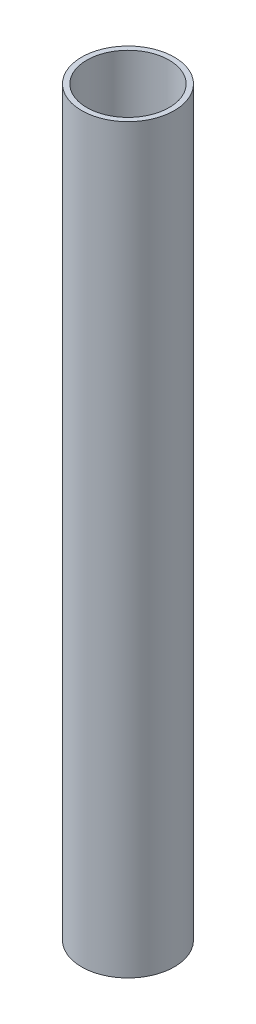
from build123d import *

# Parameters (mm, degrees)
SKETCH1_R           = 6.35
SKETCH1_R_2         = 5.6388
BOSS_EXTRUDE1_DEPTH = 101.6


with BuildPart() as part:
    # Sketch1 → Boss-Extrude1 (new body)
    with BuildSketch(Plane(origin=(0, 0, 0), x_dir=(1, 0, 0), z_dir=(0, 1, 0))):
        Circle(SKETCH1_R)
        Circle(SKETCH1_R_2, mode=Mode.SUBTRACT)
    extrude(amount=BOSS_EXTRUDE1_DEPTH)


solid = part.part
